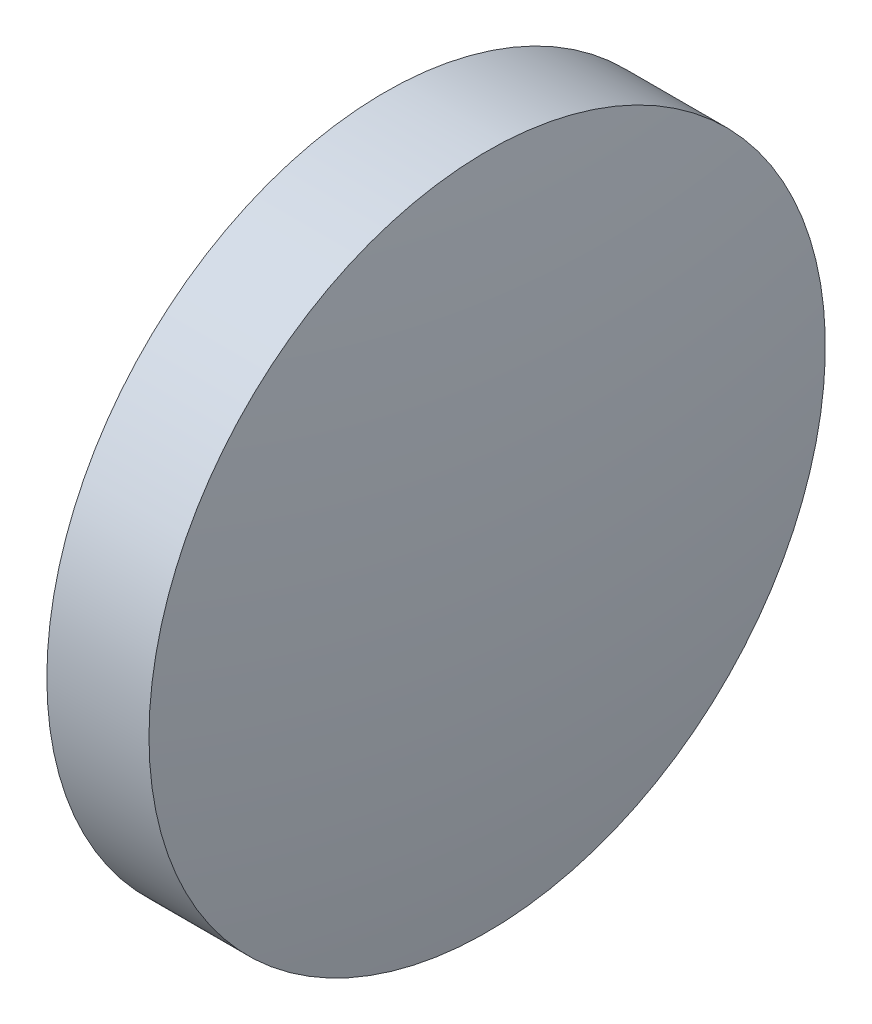
from build123d import *


with BuildPart() as part:
    # 草图1 → 旋转1 (revolve)
    with BuildSketch(Plane.XY, mode=Mode.PRIVATE) as revolve_1_sk:
        with BuildLine():
            Line((1088.591384377, 408.404729277), (1090.49138438, 408.404729277))
            ThreePointArc((1090.49138438, 408.404729277), (1090.393752958, 410.912324026), (1090.101384377, 413.404729277))
            Line((1090.101384377, 413.404729277), (1088.591384377, 413.404729277))
            Line((1088.591384377, 413.404729277), (1088.591384377, 408.404729277))
        make_face()
    revolve(revolve_1_sk.sketch.rotate(Axis((1087.359863803, 408.404729277, 0), (1, 0, 0)), 90), axis=Axis((1087.359863803, 408.404729277, 0), (1, 0, 0)))  # turned: the seam where the file's is


solid = part.part
